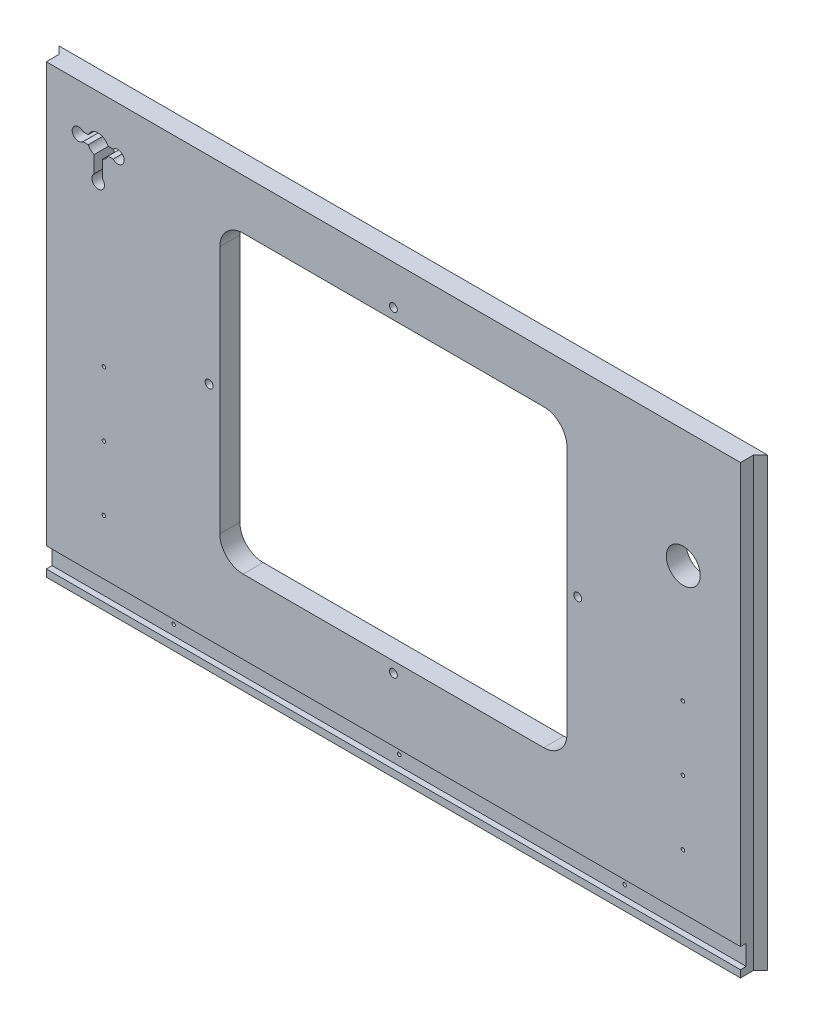
from build123d import *

# Parameters (mm, degrees)
SKETCH2_W          = 628.65
SKETCH2_H          = 396.08125
EXTRUDE1_DEPTH     = 17.78
SKETCH3_R          = 15.08125
SKETCH3_R_2        = 3.4925
SKETCH3_R_3        = 1.5875
SKETCH3_W          = 308.0004
SKETCH3_H          = 261.9629
CUT_EXTRUDE1_DEPTH = 17.78
CUT_EXTRUDE2_DEPTH = 5.08
CUT_EXTRUDE4_DEPTH = 396.08125
FILLET1_R          = 20.6502


with BuildPart() as part:
    # Sketch2 → Extrude1 (new body)
    with BuildSketch(Plane.XY):
        with Locations((12009.966666666, -5854.303125)):
            Rectangle(SKETCH2_W, SKETCH2_H)
    extrude(amount=-EXTRUDE1_DEPTH)

    # Sketch3 → Cut-Extrude1 (cut)
    with BuildSketch(Plane.XY):
        with Locations((12267.141666666, -5761.0375)):
            Circle(SKETCH3_R)
        with Locations((12173.479166666, -5831.68125)):
            Circle(SKETCH3_R_2)
        with Locations((12266.824166666, -5865.01875)):
            Circle(SKETCH3_R_3)
        with Locations((12266.824166666, -5922.16875)):
            Circle(SKETCH3_R_3)
        with Locations((12266.824166666, -5979.31875)):
            Circle(SKETCH3_R_3)
        with Locations((12209.991666666, -6037.10375)):
            Circle(SKETCH3_R_3)
        with Locations((12009.966666666, -6037.10375)):
            Circle(SKETCH3_R_3)
        with Locations((11809.941666666, -6037.10375)):
            Circle(SKETCH3_R_3)
        with Locations((11753.109166666, -5979.31875)):
            Circle(SKETCH3_R_3)
        with Locations((11753.109166666, -5922.16875)):
            Circle(SKETCH3_R_3)
        with Locations((11753.109166666, -5865.01875)):
            Circle(SKETCH3_R_3)
        with Locations((11846.454166666, -5831.68125)):
            Circle(SKETCH3_R_2)
        with Locations((12009.966666666, -5972.175)):
            Circle(SKETCH3_R_2)
        with Locations((12009.966666666, -5691.1875)):
            Circle(SKETCH3_R_2)
        with Locations((12009.966666666, -5831.68125)):
            Rectangle(SKETCH3_W, SKETCH3_H)
        with BuildLine():
            Line((11734.654409808, -5693.754968556), (11739.23011943, -5693.754968556))
            ThreePointArc((11739.23011943, -5693.754968556), (11748.029166666, -5687.976468556), (11756.828213901, -5693.754968556))
            Line((11756.828213901, -5693.754968556), (11761.386355753, -5693.754968556))
            ThreePointArc((11761.386355753, -5693.754968556), (11767.531113043, -5692.357368906), (11771.079666666, -5697.564968556))
            ThreePointArc((11771.079666666, -5697.564968556), (11767.531113043, -5702.772568206), (11761.386355753, -5701.374968556))
            Line((11761.386355753, -5701.374968556), (11756.828213901, -5701.374968556))
            ThreePointArc((11756.828213901, -5701.374968556), (11754.760305425, -5704.393665595), (11751.712166666, -5706.417925308))
            Line((11751.712166666, -5706.417925308), (11751.712166666, -5721.30243896))
            ThreePointArc((11751.712166666, -5721.30243896), (11748.029166666, -5731.092968556), (11744.346166666, -5721.30243896))
            Line((11744.346166666, -5721.30243896), (11744.346166666, -5706.417925308))
            ThreePointArc((11744.346166666, -5706.417925308), (11741.298027907, -5704.393665595), (11739.23011943, -5701.374968556))
            Line((11739.23011943, -5701.374968556), (11734.654409809, -5701.374968556))
            ThreePointArc((11734.654409809, -5701.374968556), (11724.978666666, -5697.564968556), (11734.654409808, -5693.754968556))
        make_face()
    extrude(amount=-CUT_EXTRUDE1_DEPTH, mode=Mode.SUBTRACT)

    # Sketch4 → Cut-Extrude2 (cut)
    with BuildSketch(Plane.XY):
        Polygon((11975.041666666, -6028.21375), (11695.641666666, -6028.21375), (11695.641666666, -6045.99375), (12324.291666666, -6045.99375), (12324.291666666, -6028.21375), align=None)
    extrude(amount=-CUT_EXTRUDE2_DEPTH, mode=Mode.SUBTRACT)

    # Sketch7 → Cut-Extrude4 (cut)
    with BuildSketch(Plane.XZ.offset(6052.34375)):
        Polygon((11701.991666666, -11.43), (11701.991666666, 0), (11695.641666666, 0), (11695.641666666, -17.78), align=None)
        Polygon((12317.941666666, -11.43), (12324.291666666, -17.78), (12324.291666666, 0), (12317.941666666, 0), align=None)
    extrude(amount=-CUT_EXTRUDE4_DEPTH, mode=Mode.SUBTRACT)

    # Fillet1
    fillet1_edges = [part.edges().sort_by_distance(p)[0] for p in [
        (11855.966466666, -5962.6627, -8.89),
        (11855.966466666, -5700.6998, -8.89),
        (12163.966866666, -5700.6998, -8.89),
        (12163.966866666, -5962.6627, -8.89),
    ]]
    fillet(fillet1_edges, radius=FILLET1_R)


solid = part.part
